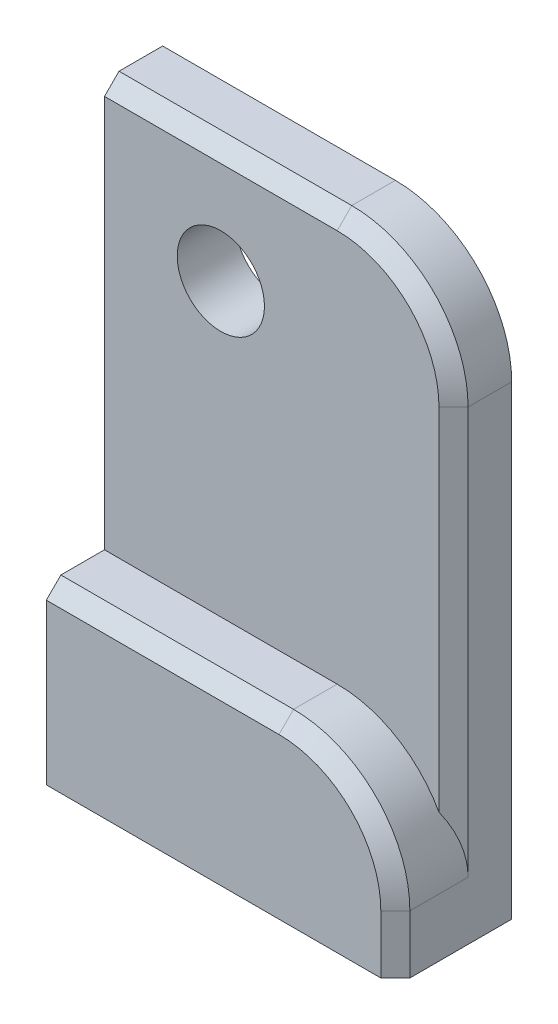
from build123d import *

# Parameters (mm, degrees)
SKETCH1_W           = 60
SKETCH1_H           = 100
BOSS_EXTRUDE2_DEPTH = 10
SKETCH4_W           = 60
SKETCH4_H           = 30
BOSS_EXTRUDE3_DEPTH = 10
SKETCH5_R           = 7.5
CUT_EXTRUDE1_DEPTH  = 118.046999107
FILLET1_R           = 20
CHAMFER1_SIZE       = 2.5
SHELL3_T            = -2


with BuildPart() as part:
    # Sketch1 → Boss-Extrude2 (new body)
    with BuildSketch(Plane.XY):
        with Locations((30, 50)):
            Rectangle(SKETCH1_W, SKETCH1_H)
    extrude(amount=BOSS_EXTRUDE2_DEPTH)

    # Sketch4 → Boss-Extrude3 (add)
    with BuildSketch(Plane.XY.offset(10)):
        with Locations((30, 15)):
            Rectangle(SKETCH4_W, SKETCH4_H)
    extrude(amount=BOSS_EXTRUDE3_DEPTH)

    # Sketch5 → Cut-Extrude1 (cut, through all)
    with BuildSketch(Plane.XY.offset(10)):
        with Locations((20, 80)):
            Circle(SKETCH5_R)
    extrude(amount=-CUT_EXTRUDE1_DEPTH, mode=Mode.SUBTRACT)

    # Fillet1
    fillet1_edges = [part.edges().sort_by_distance(p)[0] for p in [
        (60, 30, 15),
        (60, 100, 5),
    ]]
    fillet(fillet1_edges, radius=FILLET1_R)

    # Chamfer1
    chamfer1_edges = [part.edges().sort_by_distance(p)[0] for p in [
        (60, 45, 10),
        (60, 5, 20),
        (20, 30, 20),
        (54.142135624, 24.142135624, 20),
        (20, 100, 10),
        (54.142135624, 94.142135624, 10),
    ]]
    chamfer(chamfer1_edges, length=CHAMFER1_SIZE)

    # Shell3
    shell3_openings = [part.faces().sort_by_distance(p)[0] for p in [
        (29.925995833, 48.394756988, 0),
        (29.923846823, 0, 9.976066144),
        (0, 41.815619968, 7.274557166),
    ]]
    offset(amount=SHELL3_T, openings=shell3_openings, kind=Kind.INTERSECTION)


solid = part.part
